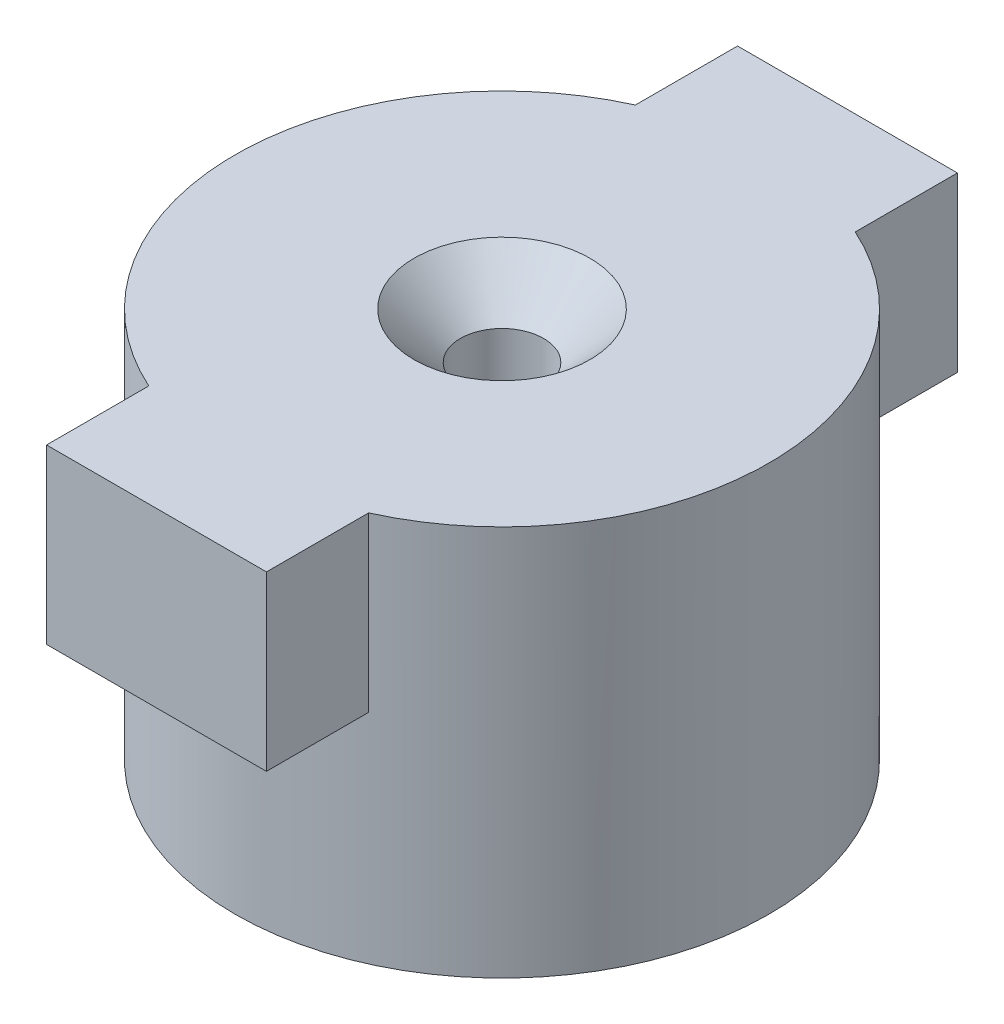
from build123d import *

# Parameters (mm, degrees)
SKETCH1_R                     = 17
BOSS_EXTRUDE1_DEPTH           = 24.88
SKETCH2_W                     = 14
SKETCH2_H                     = 44
BOSS_EXTRUDE2_DEPTH           = 11
CSK_FOR_M5_SFHCS1_D           = 5.3
CSK_FOR_M5_SFHCS1_CSINK_D     = 11.2
CSK_FOR_M5_SFHCS1_CSINK_ANGLE = 90


with BuildPart() as part:
    # Sketch1 → Boss-Extrude1 (new body)
    with BuildSketch(Plane(origin=(0, 0, 0), x_dir=(1, 0, 0), z_dir=(0, 1, 0))):
        Circle(SKETCH1_R)
    extrude(amount=BOSS_EXTRUDE1_DEPTH)

    # Sketch2 → Boss-Extrude2 (add)
    with BuildSketch(Plane(origin=(0, 24.88, 0), x_dir=(1, 0, 0), z_dir=(0, 1, 0))):
        Rectangle(SKETCH2_W, SKETCH2_H)
    extrude(amount=-BOSS_EXTRUDE2_DEPTH)

    # CSK for M5 SFHCS1 (through all)
    with Locations(Plane(origin=(0, 24.88, 0), x_dir=(1, 0, 0), z_dir=(0, 1, 0))):
        with Locations((0, 0)):
            CounterSinkHole(CSK_FOR_M5_SFHCS1_D / 2, CSK_FOR_M5_SFHCS1_CSINK_D / 2, counter_sink_angle=CSK_FOR_M5_SFHCS1_CSINK_ANGLE)


solid = part.part
